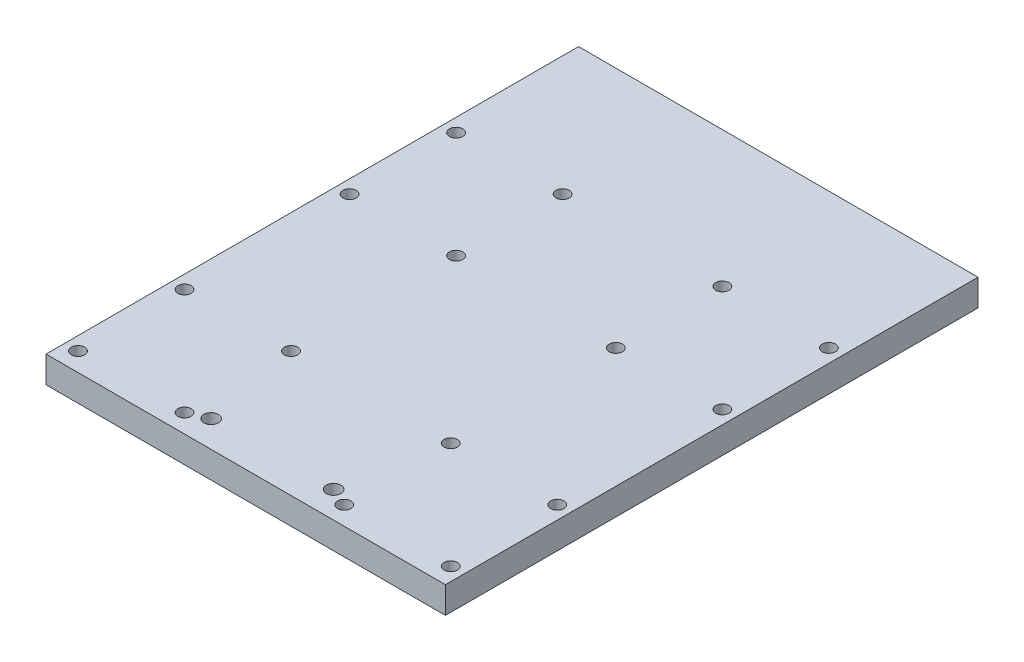
from build123d import *

# Parameters (mm, degrees)
SKETCH1_W           = 150
SKETCH1_H           = 200
BOSS_EXTRUDE1_DEPTH = 10
SKETCH2_R           = 2.5
SKETCH2_R_2         = 2.75
CUT_EXTRUDE1_DEPTH  = 11


with BuildPart() as part:
    # Sketch1 → Boss-Extrude1 (new body)
    with BuildSketch(Plane(origin=(0, 0, 0), x_dir=(1, 0, 0), z_dir=(0, 1, 0))):
        Rectangle(SKETCH1_W, SKETCH1_H)
    extrude(amount=BOSS_EXTRUDE1_DEPTH)

    # Sketch2 → Cut-Extrude1 (cut, through all)
    with BuildSketch(Plane.XZ):
        with Locations((-70, 93)):
            Circle(SKETCH2_R)
        with Locations((-30, 93)):
            Circle(SKETCH2_R)
        with Locations((-30, 53)):
            Circle(SKETCH2_R)
        with Locations((-70, 53)):
            Circle(SKETCH2_R)
        with Locations((70, 53)):
            Circle(SKETCH2_R)
        with Locations((30, 53)):
            Circle(SKETCH2_R)
        with Locations((30, 93)):
            Circle(SKETCH2_R)
        with Locations((70, 93)):
            Circle(SKETCH2_R)
        with Locations((-70, -9)):
            Circle(SKETCH2_R)
        with Locations((-30, -9)):
            Circle(SKETCH2_R)
        with Locations((-30, -49)):
            Circle(SKETCH2_R)
        with Locations((-70, -49)):
            Circle(SKETCH2_R)
        with Locations((70, -49)):
            Circle(SKETCH2_R)
        with Locations((30, -49)):
            Circle(SKETCH2_R)
        with Locations((30, -9)):
            Circle(SKETCH2_R)
        with Locations((70, -9)):
            Circle(SKETCH2_R)
        with Locations((-23, 90)):
            Circle(SKETCH2_R_2)
        with Locations((23, 90)):
            Circle(SKETCH2_R_2)
    extrude(amount=-CUT_EXTRUDE1_DEPTH, mode=Mode.SUBTRACT)


solid = part.part
